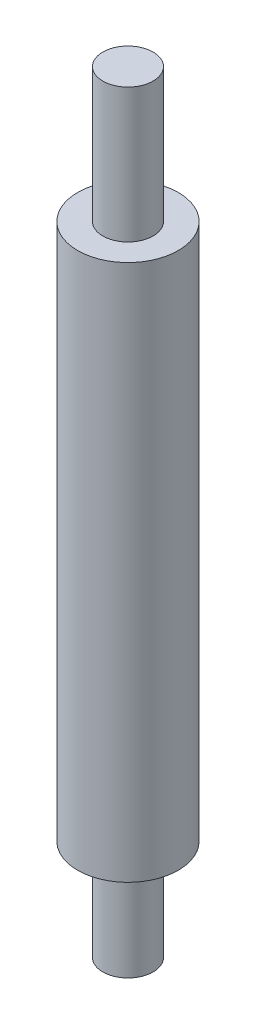
from build123d import *

# Parameters (mm, degrees)
SKETCH1_R           = 1.5
BOSS_EXTRUDE1_DEPTH = 6
SKETCH2_R           = 3
BOSS_EXTRUDE2_DEPTH = 32
SKETCH3_R           = 1.5
BOSS_EXTRUDE3_DEPTH = 8


with BuildPart() as part:
    # Sketch1 → Boss-Extrude1 (new body)
    with BuildSketch(Plane(origin=(0, 0, 0), x_dir=(1, 0, 0), z_dir=(0, 1, 0))):
        Circle(SKETCH1_R)
    extrude(amount=BOSS_EXTRUDE1_DEPTH)

    # Sketch2 → Boss-Extrude2 (add)
    with BuildSketch(Plane(origin=(0, 6, 0), x_dir=(1, 0, 0), z_dir=(0, 1, 0))):
        Circle(SKETCH2_R)
    extrude(amount=BOSS_EXTRUDE2_DEPTH)

    # Sketch3 → Boss-Extrude3 (add)
    with BuildSketch(Plane(origin=(0, 38, 0), x_dir=(1, 0, 0), z_dir=(0, 1, 0))):
        Circle(SKETCH3_R)
    extrude(amount=BOSS_EXTRUDE3_DEPTH)


solid = part.part
